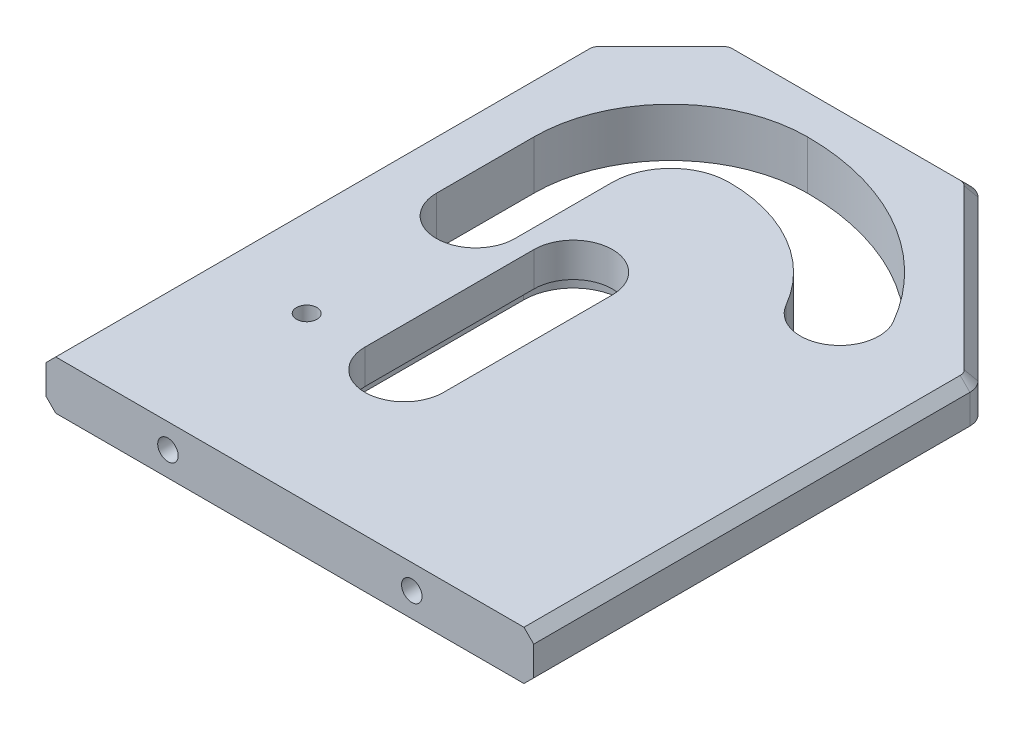
from build123d import *

# Parameters (mm, degrees)
SKETCH1_W                 = 100
SKETCH1_H                 = 126.094412
BOSS_EXTRUDE1_DEPTH       = 5
SLOTS_DEPTH               = 11
CUT_EXTRUDE6_DEPTH        = 3
M5X0_8_TAPPED_HOLE2_D     = 4.2
SKETCH13_R                = 4.15
CUT_EXTRUDE7_DEPTH        = 5
M5X0_8_TAPPED_HOLE1_D     = 4.2
M5X0_8_TAPPED_HOLE1_DEPTH = 20
M5X0_8_TAPPED_HOLE1_TIP   = 1.2618073
CUT_EXTRUDE2_DEPTH        = 11
CUT_EXTRUDE3_DEPTH        = 11
FILLET1_R                 = 4
CHAMFER1_SIZE             = 2


with BuildPart() as part:
    # Sketch1 → Boss-Extrude1 (new body, symmetric)
    with BuildSketch(Plane(origin=(0, 0, 0), x_dir=(1, 0, 0), z_dir=(0, 1, 0))):
        with Locations((10, -5.047206)):
            Rectangle(SKETCH1_W, SKETCH1_H)
    extrude(amount=BOSS_EXTRUDE1_DEPTH, both=True)

    # Sketch3 → Slots (cut, through all)
    with BuildSketch(Plane(origin=(0, 5, 0), x_dir=(1, 0, 0), z_dir=(0, 1, 0))):
        with BuildLine():
            Line((-8.05, 0), (-8.05, -34.641016151))
            ThreePointArc((-8.05, -34.641016151), (0, -42.691016151), (8.05, -34.641016151))
            Line((8.05, -34.641016151), (8.05, 0))
            ThreePointArc((8.05, 0), (0, 8.05), (-8.05, 0))
        make_face()
        with BuildLine():
            Line((-11.95, 0), (-11.95, 20))
            ThreePointArc((-11.95, 20), (-8.449926035, 28.449926035), (0, 31.95))
            ThreePointArc((0, 31.95), (15.975, 27.669511651), (27.669511651, 15.975))
            ThreePointArc((27.669511651, 15.975), (38.666016151, 13.0284955), (41.612520652, 24.025))
            ThreePointArc((41.612520652, 24.025), (24.025, 41.612520652), (0, 48.05))
            ThreePointArc((0, 48.05), (-19.834345212, 39.834345212), (-28.05, 20))
            Line((-28.05, 20), (-28.05, 0))
            ThreePointArc((-28.05, 0), (-20, -8.05), (-11.95, 0))
        make_face()
    extrude(amount=-SLOTS_DEPTH, mode=Mode.SUBTRACT)

    # Sketch12 → Cut-Extrude6 (cut)
    with BuildSketch(Plane.XZ.offset(5)):
        with BuildLine():
            Line((10.15, 0), (10.15, 34.641016151))
            ThreePointArc((10.15, 34.641016151), (0, 44.791016151), (-10.15, 34.641016151))
            Line((-10.15, 34.641016151), (-10.15, 0))
            ThreePointArc((-10.15, 0), (0, -10.15), (10.15, 0))
        make_face()
    extrude(amount=-CUT_EXTRUDE6_DEPTH, mode=Mode.SUBTRACT)

    # M5x0.8 Tapped Hole2 (through all)
    with Locations(Plane(origin=(0, 5, 0), x_dir=(1, 0, 0), z_dir=(0, 1, 0))):
        with Locations((-20, -34.641016151)):
            Hole(M5X0_8_TAPPED_HOLE2_D / 2)

    # Sketch13 → Cut-Extrude7 (cut)
    with BuildSketch(Plane.XZ.offset(5)):
        with Locations((-20, 34.641016151)):
            Circle(SKETCH13_R)
    extrude(amount=-CUT_EXTRUDE7_DEPTH, mode=Mode.SUBTRACT)

    # M5x0.8 Tapped Hole1
    with Locations(Plane.XY.offset(68.094412)):
        with Locations((-15, 0), (35, 0)):
            Hole(M5X0_8_TAPPED_HOLE1_D / 2, depth=M5X0_8_TAPPED_HOLE1_DEPTH)
            with Locations((0, 0, -(M5X0_8_TAPPED_HOLE1_DEPTH + M5X0_8_TAPPED_HOLE1_TIP / 2))):  # 118° drill point
                Cone(0, M5X0_8_TAPPED_HOLE1_D / 2, M5X0_8_TAPPED_HOLE1_TIP, mode=Mode.SUBTRACT)

    # Sketch4 → Cut-Extrude2 (cut, through all)
    with BuildSketch(Plane(origin=(0, 5, 0), x_dir=(1, 0, 0), z_dir=(0, 1, 0))):
        Polygon((-40, 43), (-40, 58), (-25, 58), align=None)
    extrude(amount=-CUT_EXTRUDE2_DEPTH, mode=Mode.SUBTRACT)

    # Sketch5 → Cut-Extrude3 (cut, through all)
    with BuildSketch(Plane(origin=(0, 5, 0), x_dir=(1, 0, 0), z_dir=(0, 1, 0))):
        Polygon((25, 58), (60, 58), (60, 23), align=None)
    extrude(amount=-CUT_EXTRUDE3_DEPTH, mode=Mode.SUBTRACT)

    # Fillet1
    fillet1_edges = [part.edges().sort_by_distance(p)[0] for p in [
        (-25, 0, -58),
        (-40, 0, -43),
        (60, 0, -23),
        (25, 0, -58),
    ]]
    fillet(fillet1_edges, radius=FILLET1_R)

    # Chamfer1
    chamfer1_edges = [part.edges().sort_by_distance(p)[0] for p in [
        (42.5, 5, -40.5),
        (0, 5, -58),
        (-32.5, 5, -50.5),
        (-40, 5, 13.375633125),
        (-39.69551813, 5, -42.87387948),
        (-24.87387948, 5, -57.69551813),
        (24.87387948, 5, -57.69551813),
        (59.69551813, 5, -22.87387948),
        (60, 5, 23.375633125),
        (42.5, -5, -40.5),
        (-40, -5, 13.375633125),
        (-32.5, -5, -50.5),
        (0, -5, -58),
        (-39.69551813, -5, -42.87387948),
        (-24.87387948, -5, -57.69551813),
        (24.87387948, -5, -57.69551813),
        (59.69551813, -5, -22.87387948),
        (60, -5, 23.375633125),
    ]]
    chamfer(chamfer1_edges, length=CHAMFER1_SIZE)


solid = part.part
